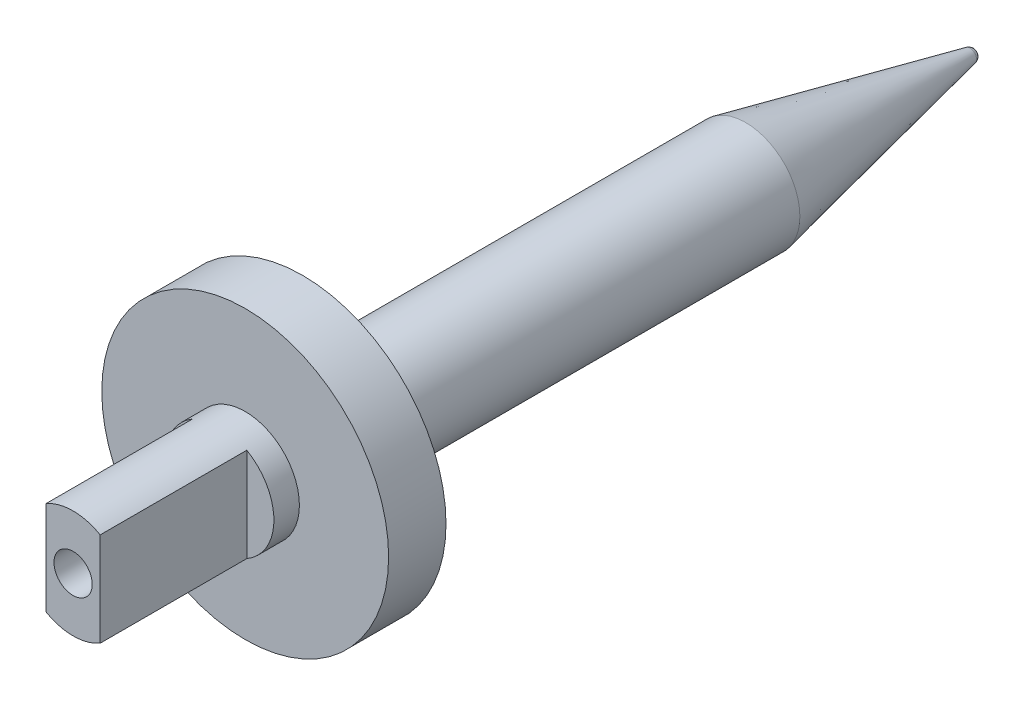
from build123d import *
from build123d.topology import SkipClean

# Parameters (mm, degrees)
SKETCH1_R                 = 8.5
BASE_EXTRUDE_DEPTH        = 110
SKETCH1_4_R               = 22.5
FRONT_CAP_DEPTH           = 4.5
END_BEVEL_FILLET_R        = 1
SKETCH7_R                 = 8.5
FRONT_KNOB_DEPTH          = 4
FRONT_KNOB_SLOT_DEPTH     = 23
M7X1_0_TAPPED_HOLE1_D     = 6
M7X1_0_TAPPED_HOLE1_DEPTH = 19
M7X1_0_TAPPED_HOLE1_TIP   = 1.802581857


with BuildPart() as part:
    # Sketch1 → Base Extrude (new body)
    with BuildSketch(Plane.XY):
        Circle(SKETCH1_R)
    extrude(amount=-BASE_EXTRUDE_DEPTH)

    # Sketch1_4 → Front Cap (add, symmetric)
    with BuildSketch(Plane.XY):
        Circle(SKETCH1_4_R)
    extrude(amount=FRONT_CAP_DEPTH, both=True)

    # Sketch3 → End Bevel (revolve, cut)
    with BuildSketch(Plane(origin=(0, 0, 0), x_dir=(0, 0, -1), z_dir=(1, 0, 0)), mode=Mode.PRIVATE) as end_bevel_sk:
        Polygon((74.010644069, 8.5), (114, 0), (124.010644069, 0), (124.010644069, 25), (74.010644069, 25), align=None)
    revolve(end_bevel_sk.sketch.rotate(Axis((0, 0, -92.509493434), (0, 0, -1)), 90), axis=Axis((0, 0, -92.509493434), (0, 0, -1)), mode=Mode.SUBTRACT)  # turned: the seam where the file's is

    # End Bevel Fillet
    end_bevel_fillet_edges = [part.edges().sort_by_distance(p)[0] for p in [
        (-0.850226247, 0, -110),
    ]]
    fillet(end_bevel_fillet_edges, radius=END_BEVEL_FILLET_R)

    # Sketch7 → Front Knob (add)
    with BuildSketch(Plane.XY.offset(4.5)):
        Circle(SKETCH7_R)
    extrude(amount=FRONT_KNOB_DEPTH)

    # Sketch6 → Front Knob Slot (add)
    with SkipClean():  # keep this step's faces unmerged: merging them makes the solid invalid here
        with BuildSketch(Plane.XY.offset(8.5)):
            with BuildLine():
                Line((-4.25, -7.361215932), (-4.25, 7.361215932))
                ThreePointArc((-4.25, 7.361215932), (0, 8.5), (4.25, 7.361215932))
                Line((4.25, 7.361215932), (4.25, -7.361215932))
                ThreePointArc((4.25, -7.361215932), (0, -8.5), (-4.25, -7.361215932))
            make_face()
        extrude(amount=FRONT_KNOB_SLOT_DEPTH)

    # M7x1.0 Tapped Hole1
    with Locations(Plane.XY.offset(31.5)):
        with Locations((0, 0)):
            Hole(M7X1_0_TAPPED_HOLE1_D / 2, depth=M7X1_0_TAPPED_HOLE1_DEPTH)
            with Locations((0, 0, -(M7X1_0_TAPPED_HOLE1_DEPTH + M7X1_0_TAPPED_HOLE1_TIP / 2))):  # 118° drill point
                Cone(0, M7X1_0_TAPPED_HOLE1_D / 2, M7X1_0_TAPPED_HOLE1_TIP, mode=Mode.SUBTRACT)


solid = part.part
